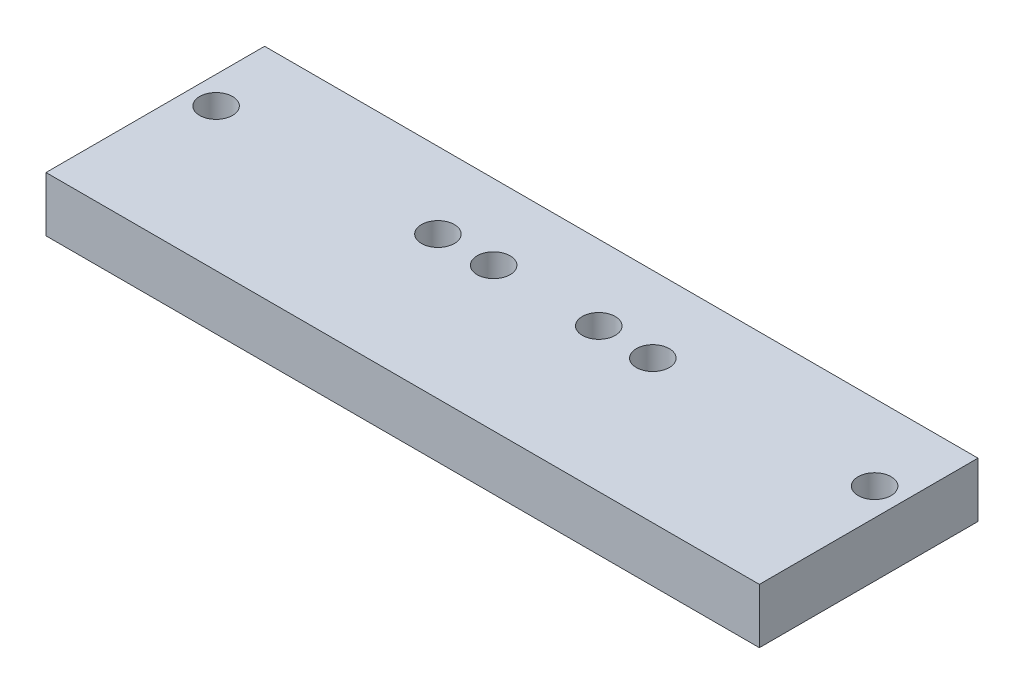
from build123d import *

# Parameters (mm, degrees)
SKETCH1_W           = 130
SKETCH1_H           = 39.84
BOSS_EXTRUDE1_DEPTH = 10
SKETCH2_R           = 3
CUT_EXTRUDE1_DEPTH  = 11


with BuildPart() as part:
    # Sketch1 → Boss-Extrude1 (new body)
    with BuildSketch(Plane(origin=(0, 0, 0), x_dir=(1, 0, 0), z_dir=(0, 1, 0))):
        with Locations((65, 19.92)):
            Rectangle(SKETCH1_W, SKETCH1_H)
    extrude(amount=BOSS_EXTRUDE1_DEPTH)

    # Sketch2 → Cut-Extrude1 (cut, through all)
    with BuildSketch(Plane(origin=(0, 10, 0), x_dir=(1, 0, 0), z_dir=(0, 1, 0))):
        with Locations((5, 25.999053891)):
            Circle(SKETCH2_R)
        with Locations((45.42, 25.999053891)):
            Circle(SKETCH2_R)
        with Locations((55.42, 26.150756349)):
            Circle(SKETCH2_R)
        with Locations((74.58, 26.150756349)):
            Circle(SKETCH2_R)
        with Locations((84.58, 25.999053891)):
            Circle(SKETCH2_R)
        with Locations((125, 25.999053891)):
            Circle(SKETCH2_R)
    extrude(amount=-CUT_EXTRUDE1_DEPTH, mode=Mode.SUBTRACT)


solid = part.part
